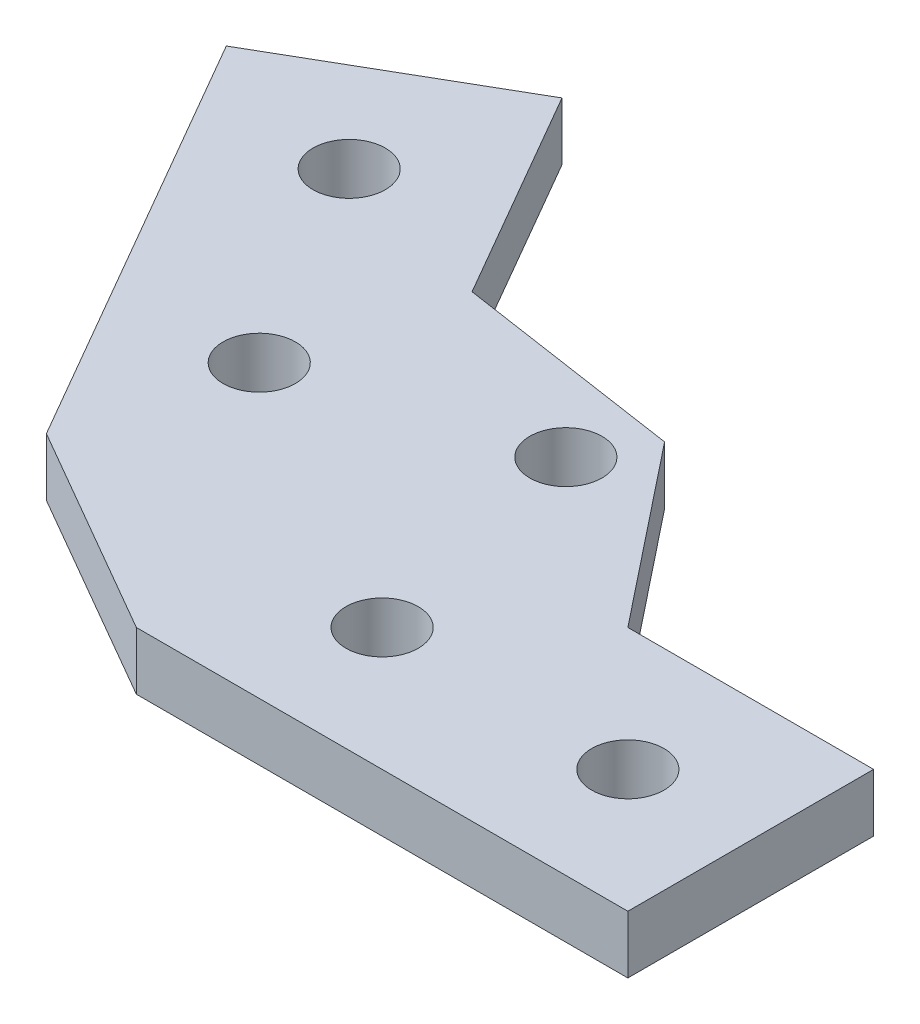
from build123d import *

# Parameters (mm, degrees)
SKETCH1_W           = 34
SKETCH1_H           = 17
SKETCH1_R           = 2.5
BOSS_EXTRUDE1_DEPTH = 4
BOSS_EXTRUDE2_DEPTH = 4
SKETCH13_R          = 2.5
BOSS_EXTRUDE3_DEPTH = 4


with BuildPart() as part:
    # sketch1 → Boss-Extrude1 (new body)
    with BuildSketch(Plane(origin=(0, 0, 0), x_dir=(1, 0, 0), z_dir=(0, 1, 0))):
        with Locations((17, -8.5)):
            Rectangle(SKETCH1_W, SKETCH1_H)
        with Locations((8.5, -8.5)):
            Circle(SKETCH1_R, mode=Mode.SUBTRACT)
        with Locations((25.5, -8.5)):
            Circle(SKETCH1_R, mode=Mode.SUBTRACT)
    extrude(amount=BOSS_EXTRUDE1_DEPTH)


with BuildPart() as body_2:
    # Mirror6: mirrored copy
    add(part.part.mirror(Plane(origin=(0, 0, 0), x_dir=(-0.5, 0, 0.866025404), z_dir=(-0.866025404, 0, -0.5))))


with BuildPart() as part_1:
    add(part.part)

    add(body_2.part)  # Boss-Extrude2 merges body 2
    # Sketch11 → Boss-Extrude2 (add)
    with BuildSketch(Plane(origin=(0, 0, 0), x_dir=(1, 0, 0), z_dir=(0, 1, 0))):
        Polygon((-14.722431864, -8.5), (0, -17), (0, 0), align=None)
    extrude(amount=BOSS_EXTRUDE2_DEPTH)

    # Sketch13 → Boss-Extrude3 (add)
    with BuildSketch(Plane(origin=(0, 0, 0), x_dir=(1, 0, 0), z_dir=(0, 1, 0))):
        Polygon((7.152847248, 12.389094852), (-8.5, 14.722431864), (0, 0), (17, 0), align=None)
        with Locations((4.652847248, 8.058967833)):
            Circle(SKETCH13_R, mode=Mode.SUBTRACT)
    extrude(amount=BOSS_EXTRUDE3_DEPTH)


solid = part_1.part
